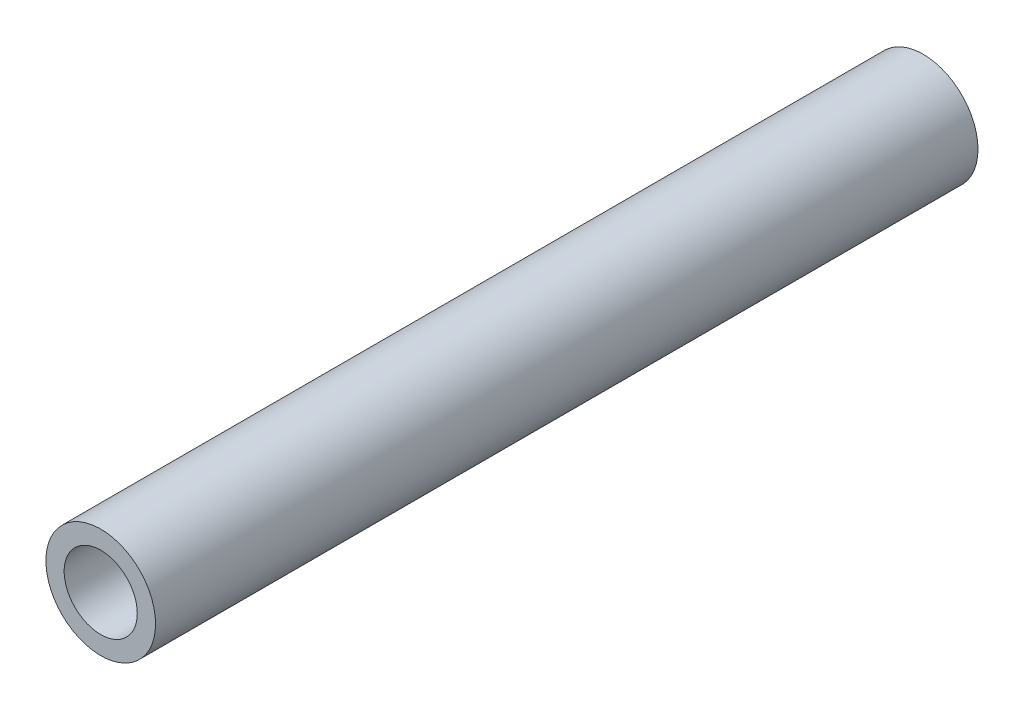
from build123d import *

# Parameters (mm, degrees)
SKETCH_1_R      = 3
SKETCH_1_R_2    = 2
EXTRUDE_1_DEPTH = 22.5


with BuildPart() as part:
    # 草图1 → 凸台-拉伸1 (new body, symmetric)
    with BuildSketch(Plane.XY):
        Circle(SKETCH_1_R)
        Circle(SKETCH_1_R_2, mode=Mode.SUBTRACT)
    extrude(amount=EXTRUDE_1_DEPTH, both=True)


solid = part.part
